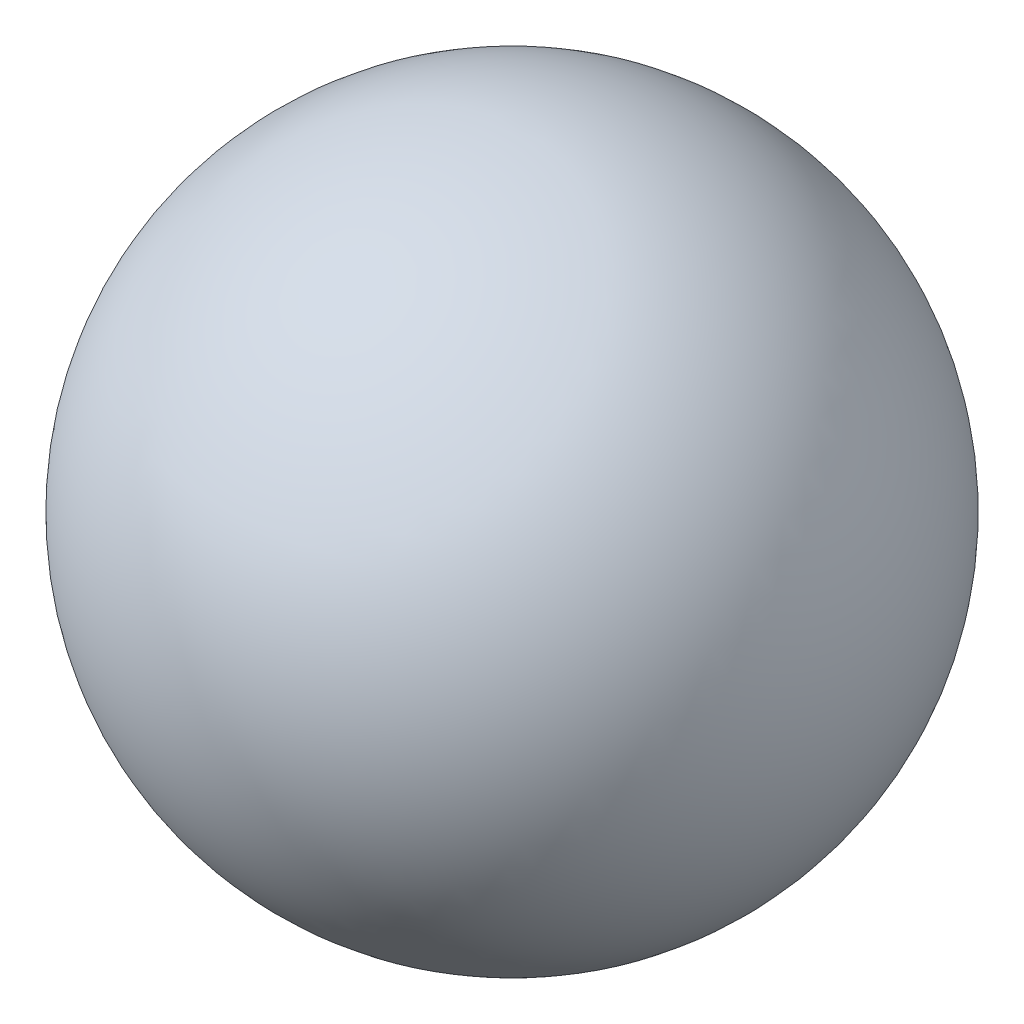
from build123d import *


with BuildPart() as part:
    # Sketch1 → Revolve1 (revolve)
    with BuildSketch(Plane.XY):
        with BuildLine():
            Line((0, 0.24), (0, -0.24))
            ThreePointArc((0, -0.24), (0.24, 0), (0, 0.24))
        make_face()
    revolve(axis=Axis((0, 0.95096652, 0), (0, -1, 0)))


solid = part.part
